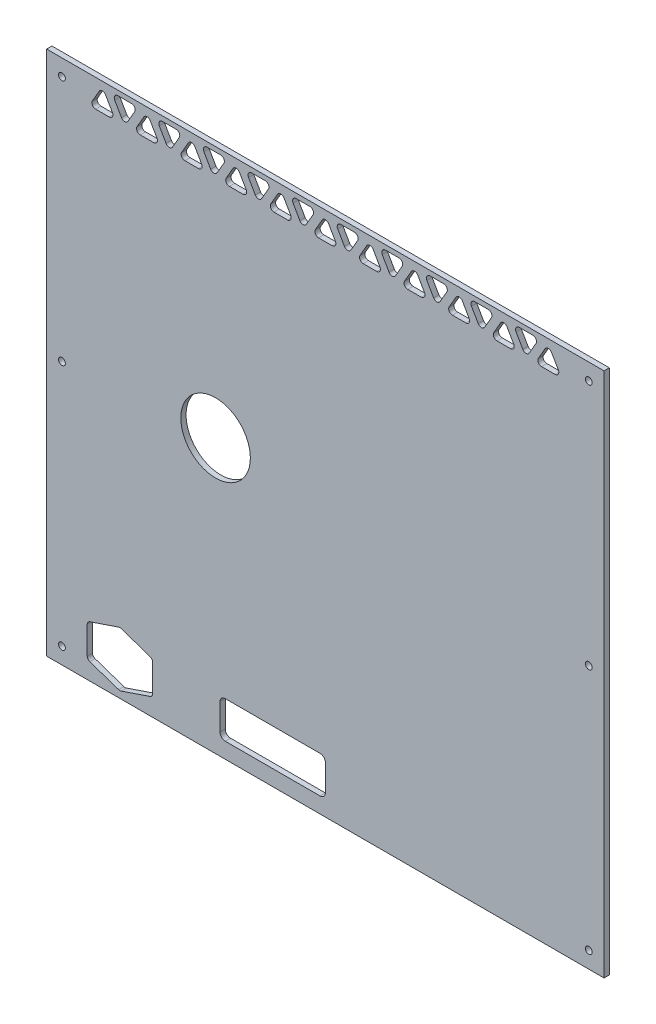
from build123d import *

# Parameters (mm, degrees)
MODEL_W             = 529
MODEL_H             = 499
MODEL_R             = 3.25
MODEL_R_2           = 33
BOSS_EXTRUDE1_DEPTH = 5


with BuildPart() as part:
    # Model → Boss-Extrude1 (new body)
    with BuildSketch(Plane.XY):
        with Locations((264.5, 249.5)):
            Rectangle(MODEL_W, MODEL_H)
        with Locations((514.5, 483.5)):
            Circle(MODEL_R, mode=Mode.SUBTRACT)
        with Locations((514.5, 249.5)):
            Circle(MODEL_R, mode=Mode.SUBTRACT)
        with Locations((14.5, 249.5)):
            Circle(MODEL_R, mode=Mode.SUBTRACT)
        with Locations((514.5, 15.5)):
            Circle(MODEL_R, mode=Mode.SUBTRACT)
        with Locations((14.5, 483.5)):
            Circle(MODEL_R, mode=Mode.SUBTRACT)
        with Locations((14.5, 15.5)):
            Circle(MODEL_R, mode=Mode.SUBTRACT)
        with Locations((160.3, 259.55)):
            Circle(MODEL_R_2, mode=Mode.SUBTRACT)
        with BuildLine():
            Line((80.497865533, 494.5), (67.622221186, 494.5))
            ThreePointArc((67.622221186, 494.5), (64.591132273, 492.75), (64.591132273, 489.25))
            Line((64.591132273, 489.25), (71.028954446, 478.099364905))
            ThreePointArc((71.028954446, 478.099364905), (74.06004336, 476.349364905), (77.091132273, 478.099364905))
            Line((77.091132273, 478.099364905), (83.528954446, 489.25))
            ThreePointArc((83.528954446, 489.25), (83.528954446, 492.75), (80.497865533, 494.5))
        make_face(mode=Mode.SUBTRACT)
        with BuildLine():
            Line((62.368911087, 478.099), (55.931088913, 489.249635095))
            ThreePointArc((55.931088913, 489.249635095), (52.9, 490.999635095), (49.868911087, 489.249635095))
            Line((49.868911087, 489.249635095), (43.431088913, 478.099))
            ThreePointArc((43.431088913, 478.099), (43.431088913, 474.599), (46.462177826, 472.849))
            Line((46.462177826, 472.849), (59.337822174, 472.849))
            ThreePointArc((59.337822174, 472.849), (62.368911087, 474.599), (62.368911087, 478.099))
        make_face(mode=Mode.SUBTRACT)
        with BuildLine():
            Line((104.688997643, 478.099), (98.251175469, 489.249635095))
            ThreePointArc((98.251175469, 489.249635095), (95.220086556, 490.999635095), (92.188997643, 489.249635095))
            Line((92.188997643, 489.249635095), (85.751175469, 478.099))
            ThreePointArc((85.751175469, 478.099), (85.751175469, 474.599), (88.782264382, 472.849))
            Line((88.782264382, 472.849), (101.65790873, 472.849))
            ThreePointArc((101.65790873, 472.849), (104.688997643, 474.599), (104.688997643, 478.099))
        make_face(mode=Mode.SUBTRACT)
        with BuildLine():
            Line((147.009084199, 478.099), (140.571262025, 489.249635095))
            ThreePointArc((140.571262025, 489.249635095), (137.540173112, 490.999635095), (134.509084199, 489.249635095))
            Line((134.509084199, 489.249635095), (128.071262025, 478.099))
            ThreePointArc((128.071262025, 478.099), (128.071262025, 474.599), (131.102350938, 472.849))
            Line((131.102350938, 472.849), (143.977995286, 472.849))
            ThreePointArc((143.977995286, 472.849), (147.009084199, 474.599), (147.009084199, 478.099))
        make_face(mode=Mode.SUBTRACT)
        with BuildLine():
            Line((189.329170755, 478.099), (182.891348581, 489.249635095))
            ThreePointArc((182.891348581, 489.249635095), (179.860259668, 490.999635095), (176.829170755, 489.249635095))
            Line((176.829170755, 489.249635095), (170.391348581, 478.099))
            ThreePointArc((170.391348581, 478.099), (170.391348581, 474.599), (173.422437494, 472.849))
            Line((173.422437494, 472.849), (186.298081842, 472.849))
            ThreePointArc((186.298081842, 472.849), (189.329170755, 474.599), (189.329170755, 478.099))
        make_face(mode=Mode.SUBTRACT)
        with BuildLine():
            Line((231.649257311, 478.099), (225.211435137, 489.249635095))
            ThreePointArc((225.211435137, 489.249635095), (222.180346224, 490.999635095), (219.149257311, 489.249635095))
            Line((219.149257311, 489.249635095), (212.711435137, 478.099))
            ThreePointArc((212.711435137, 478.099), (212.711435137, 474.599), (215.74252405, 472.849))
            Line((215.74252405, 472.849), (228.618168398, 472.849))
            ThreePointArc((228.618168398, 472.849), (231.649257311, 474.599), (231.649257311, 478.099))
        make_face(mode=Mode.SUBTRACT)
        with BuildLine():
            Line((273.969343867, 478.099), (267.531521693, 489.249635095))
            ThreePointArc((267.531521693, 489.249635095), (264.50043278, 490.999635095), (261.469343867, 489.249635095))
            Line((261.469343867, 489.249635095), (255.031521693, 478.099))
            ThreePointArc((255.031521693, 478.099), (255.031521693, 474.599), (258.062610606, 472.849))
            Line((258.062610606, 472.849), (270.938254954, 472.849))
            ThreePointArc((270.938254954, 472.849), (273.969343867, 474.599), (273.969343867, 478.099))
        make_face(mode=Mode.SUBTRACT)
        with BuildLine():
            Line((316.289430423, 478.099), (309.851608249, 489.249635095))
            ThreePointArc((309.851608249, 489.249635095), (306.820519336, 490.999635095), (303.789430423, 489.249635095))
            Line((303.789430423, 489.249635095), (297.351608249, 478.099))
            ThreePointArc((297.351608249, 478.099), (297.351608249, 474.599), (300.382697162, 472.849))
            Line((300.382697162, 472.849), (313.25834151, 472.849))
            ThreePointArc((313.25834151, 472.849), (316.289430423, 474.599), (316.289430423, 478.099))
        make_face(mode=Mode.SUBTRACT)
        with BuildLine():
            Line((358.609516979, 478.099), (352.171694805, 489.249635095))
            ThreePointArc((352.171694805, 489.249635095), (349.140605892, 490.999635095), (346.109516979, 489.249635095))
            Line((346.109516979, 489.249635095), (339.671694805, 478.099))
            ThreePointArc((339.671694805, 478.099), (339.671694805, 474.599), (342.702783718, 472.849))
            Line((342.702783718, 472.849), (355.578428066, 472.849))
            ThreePointArc((355.578428066, 472.849), (358.609516979, 474.599), (358.609516979, 478.099))
        make_face(mode=Mode.SUBTRACT)
        with BuildLine():
            Line((400.929603535, 478.099), (394.491781361, 489.249635095))
            ThreePointArc((394.491781361, 489.249635095), (391.460692448, 490.999635095), (388.429603535, 489.249635095))
            Line((388.429603535, 489.249635095), (381.991781361, 478.099))
            ThreePointArc((381.991781361, 478.099), (381.991781361, 474.599), (385.022870274, 472.849))
            Line((385.022870274, 472.849), (397.898514622, 472.849))
            ThreePointArc((397.898514622, 472.849), (400.929603535, 474.599), (400.929603535, 478.099))
        make_face(mode=Mode.SUBTRACT)
        with BuildLine():
            Line((443.249690091, 478.099), (436.811867917, 489.249635095))
            ThreePointArc((436.811867917, 489.249635095), (433.780779004, 490.999635095), (430.749690091, 489.249635095))
            Line((430.749690091, 489.249635095), (424.311867917, 478.099))
            ThreePointArc((424.311867917, 478.099), (424.311867917, 474.599), (427.34295683, 472.849))
            Line((427.34295683, 472.849), (440.218601178, 472.849))
            ThreePointArc((440.218601178, 472.849), (443.249690091, 474.599), (443.249690091, 478.099))
        make_face(mode=Mode.SUBTRACT)
        with BuildLine():
            Line((485.569776647, 478.099), (479.131954473, 489.249635095))
            ThreePointArc((479.131954473, 489.249635095), (476.10086556, 490.999635095), (473.069776647, 489.249635095))
            Line((473.069776647, 489.249635095), (466.631954473, 478.099))
            ThreePointArc((466.631954473, 478.099), (466.631954473, 474.599), (469.663043386, 472.849))
            Line((469.663043386, 472.849), (482.538687734, 472.849))
            ThreePointArc((482.538687734, 472.849), (485.569776647, 474.599), (485.569776647, 478.099))
        make_face(mode=Mode.SUBTRACT)
        with BuildLine():
            Line((122.817952089, 494.5), (109.942307742, 494.5))
            ThreePointArc((109.942307742, 494.5), (106.911218829, 492.75), (106.911218829, 489.25))
            Line((106.911218829, 489.25), (113.349041002, 478.099364905))
            ThreePointArc((113.349041002, 478.099364905), (116.380129916, 476.349364905), (119.411218829, 478.099364905))
            Line((119.411218829, 478.099364905), (125.849041002, 489.25))
            ThreePointArc((125.849041002, 489.25), (125.849041002, 492.75), (122.817952089, 494.5))
        make_face(mode=Mode.SUBTRACT)
        with BuildLine():
            Line((165.138038645, 494.5), (152.262394298, 494.5))
            ThreePointArc((152.262394298, 494.5), (149.231305385, 492.75), (149.231305385, 489.25))
            Line((149.231305385, 489.25), (155.669127558, 478.099364905))
            ThreePointArc((155.669127558, 478.099364905), (158.700216472, 476.349364905), (161.731305385, 478.099364905))
            Line((161.731305385, 478.099364905), (168.169127558, 489.25))
            ThreePointArc((168.169127558, 489.25), (168.169127558, 492.75), (165.138038645, 494.5))
        make_face(mode=Mode.SUBTRACT)
        with BuildLine():
            Line((207.458125201, 494.5), (194.582480854, 494.5))
            ThreePointArc((194.582480854, 494.5), (191.551391941, 492.75), (191.551391941, 489.25))
            Line((191.551391941, 489.25), (197.989214114, 478.099364905))
            ThreePointArc((197.989214114, 478.099364905), (201.020303028, 476.349364905), (204.051391941, 478.099364905))
            Line((204.051391941, 478.099364905), (210.489214114, 489.25))
            ThreePointArc((210.489214114, 489.25), (210.489214114, 492.75), (207.458125201, 494.5))
        make_face(mode=Mode.SUBTRACT)
        with BuildLine():
            Line((249.778211757, 494.5), (236.90256741, 494.5))
            ThreePointArc((236.90256741, 494.5), (233.871478497, 492.75), (233.871478497, 489.25))
            Line((233.871478497, 489.25), (240.30930067, 478.099364905))
            ThreePointArc((240.30930067, 478.099364905), (243.340389584, 476.349364905), (246.371478497, 478.099364905))
            Line((246.371478497, 478.099364905), (252.80930067, 489.25))
            ThreePointArc((252.80930067, 489.25), (252.80930067, 492.75), (249.778211757, 494.5))
        make_face(mode=Mode.SUBTRACT)
        with BuildLine():
            Line((292.098298313, 494.5), (279.222653966, 494.5))
            ThreePointArc((279.222653966, 494.5), (276.191565053, 492.75), (276.191565053, 489.25))
            Line((276.191565053, 489.25), (282.629387226, 478.099364905))
            ThreePointArc((282.629387226, 478.099364905), (285.66047614, 476.349364905), (288.691565053, 478.099364905))
            Line((288.691565053, 478.099364905), (295.129387226, 489.25))
            ThreePointArc((295.129387226, 489.25), (295.129387226, 492.75), (292.098298313, 494.5))
        make_face(mode=Mode.SUBTRACT)
        with BuildLine():
            Line((100.499636215, 45.424792003), (100.499636215, 19.292430817))
            ThreePointArc((100.499636215, 19.292430817), (99.844168795, 17.253157808), (98.123273699, 15.977700239))
            Line((98.123273699, 15.977700239), (70.623273699, 6.655666341))
            ThreePointArc((70.623273699, 6.655666341), (69.499636215, 6.470396918), (68.375998731, 6.655666341))
            Line((68.375998731, 6.655666341), (40.875998731, 15.977700239))
            ThreePointArc((40.875998731, 15.977700239), (39.155103636, 17.253157808), (38.499636215, 19.292430817))
            Line((38.499636215, 19.292430817), (38.499636215, 45.424792003))
            ThreePointArc((38.499636215, 45.424792003), (39.155103636, 47.464065011), (40.875998731, 48.739522581))
            Line((40.875998731, 48.739522581), (68.375998731, 58.061556479))
            ThreePointArc((68.375998731, 58.061556479), (69.499636215, 58.246825901), (70.623273699, 58.061556479))
            Line((70.623273699, 58.061556479), (98.123273699, 48.739522581))
            ThreePointArc((98.123273699, 48.739522581), (99.844168795, 47.464065011), (100.499636215, 45.424792003))
        make_face(mode=Mode.SUBTRACT)
        with BuildLine():
            Line((334.418384869, 494.5), (321.542740522, 494.5))
            ThreePointArc((321.542740522, 494.5), (318.511651609, 492.75), (318.511651609, 489.25))
            Line((318.511651609, 489.25), (324.949473782, 478.099364905))
            ThreePointArc((324.949473782, 478.099364905), (327.980562696, 476.349364905), (331.011651609, 478.099364905))
            Line((331.011651609, 478.099364905), (337.449473782, 489.25))
            ThreePointArc((337.449473782, 489.25), (337.449473782, 492.75), (334.418384869, 494.5))
        make_face(mode=Mode.SUBTRACT)
        with BuildLine():
            Line((376.738471425, 494.5), (363.862827078, 494.5))
            ThreePointArc((363.862827078, 494.5), (360.831738165, 492.75), (360.831738165, 489.25))
            Line((360.831738165, 489.25), (367.269560338, 478.099364905))
            ThreePointArc((367.269560338, 478.099364905), (370.300649252, 476.349364905), (373.331738165, 478.099364905))
            Line((373.331738165, 478.099364905), (379.769560338, 489.25))
            ThreePointArc((379.769560338, 489.25), (379.769560338, 492.75), (376.738471425, 494.5))
        make_face(mode=Mode.SUBTRACT)
        with BuildLine():
            Line((419.058557981, 494.5), (406.182913634, 494.5))
            ThreePointArc((406.182913634, 494.5), (403.151824721, 492.75), (403.151824721, 489.25))
            Line((403.151824721, 489.25), (409.589646894, 478.099364905))
            ThreePointArc((409.589646894, 478.099364905), (412.620735808, 476.349364905), (415.651824721, 478.099364905))
            Line((415.651824721, 478.099364905), (422.089646894, 489.25))
            ThreePointArc((422.089646894, 489.25), (422.089646894, 492.75), (419.058557981, 494.5))
        make_face(mode=Mode.SUBTRACT)
        with BuildLine():
            Line((461.378644537, 494.5), (448.50300019, 494.5))
            ThreePointArc((448.50300019, 494.5), (445.471911277, 492.75), (445.471911277, 489.25))
            Line((445.471911277, 489.25), (451.90973345, 478.099364905))
            ThreePointArc((451.90973345, 478.099364905), (454.940822364, 476.349364905), (457.971911277, 478.099364905))
            Line((457.971911277, 478.099364905), (464.40973345, 489.25))
            ThreePointArc((464.40973345, 489.25), (464.40973345, 492.75), (461.378644537, 494.5))
        make_face(mode=Mode.SUBTRACT)
        with BuildLine():
            Line((264.5, 44.85861141), (264.5, 19.85861141))
            ThreePointArc((264.5, 19.85861141), (263.035533906, 16.323077504), (259.5, 14.85861141))
            Line((259.5, 14.85861141), (169.5, 14.85861141))
            ThreePointArc((169.5, 14.85861141), (165.964466094, 16.323077504), (164.5, 19.85861141))
            Line((164.5, 19.85861141), (164.5, 44.85861141))
            ThreePointArc((164.5, 44.85861141), (165.964466094, 48.394145316), (169.5, 49.85861141))
            Line((169.5, 49.85861141), (259.5, 49.85861141))
            ThreePointArc((259.5, 49.85861141), (263.035533906, 48.394145316), (264.5, 44.85861141))
        make_face(mode=Mode.SUBTRACT)
    extrude(amount=BOSS_EXTRUDE1_DEPTH)


solid = part.part
